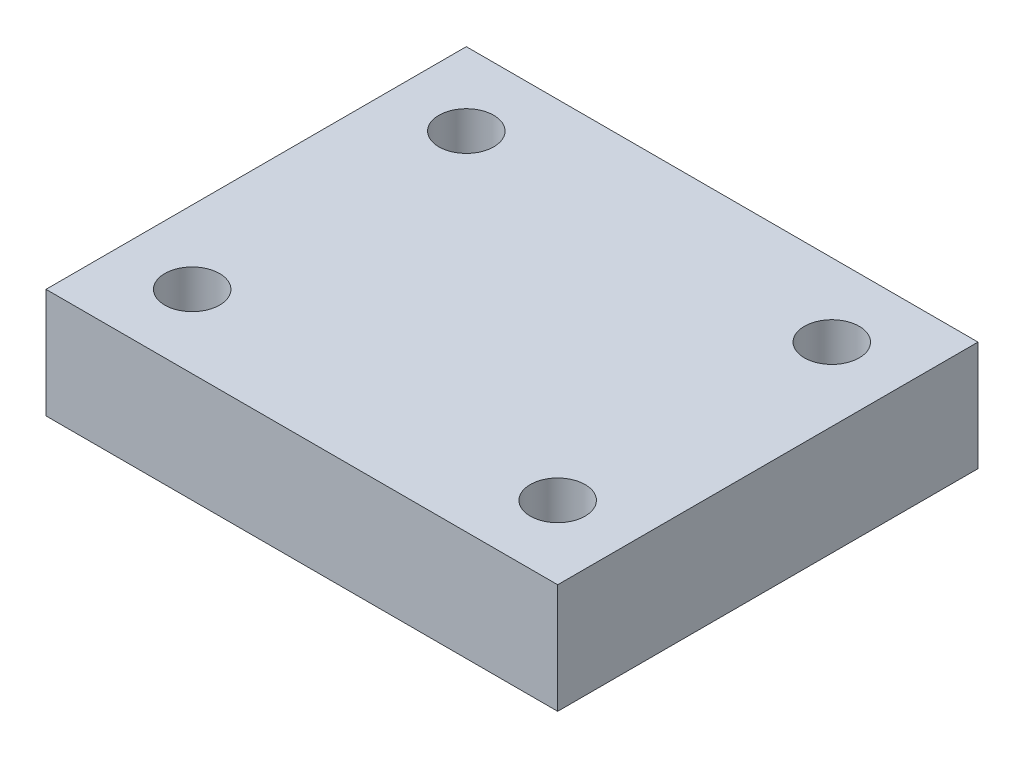
from build123d import *

# Parameters (mm, degrees)
SKETCH_1_W      = 28
SKETCH_1_H      = 23
SKETCH_1_R      = 1.5
EXTRUDE_1_DEPTH = 6


with BuildPart() as part:
    # 草图1 → 凸台-拉伸1 (new body)
    with BuildSketch(Plane(origin=(0, 0, 0), x_dir=(1, 0, 0), z_dir=(0, 1, 0))):
        Rectangle(SKETCH_1_W, SKETCH_1_H)
        with Locations((-10, 7.5)):
            Circle(SKETCH_1_R, mode=Mode.SUBTRACT)
        with Locations((10, 7.5)):
            Circle(SKETCH_1_R, mode=Mode.SUBTRACT)
        with Locations((10, -7.5)):
            Circle(SKETCH_1_R, mode=Mode.SUBTRACT)
        with Locations((-10, -7.5)):
            Circle(SKETCH_1_R, mode=Mode.SUBTRACT)
    extrude(amount=EXTRUDE_1_DEPTH)


solid = part.part
